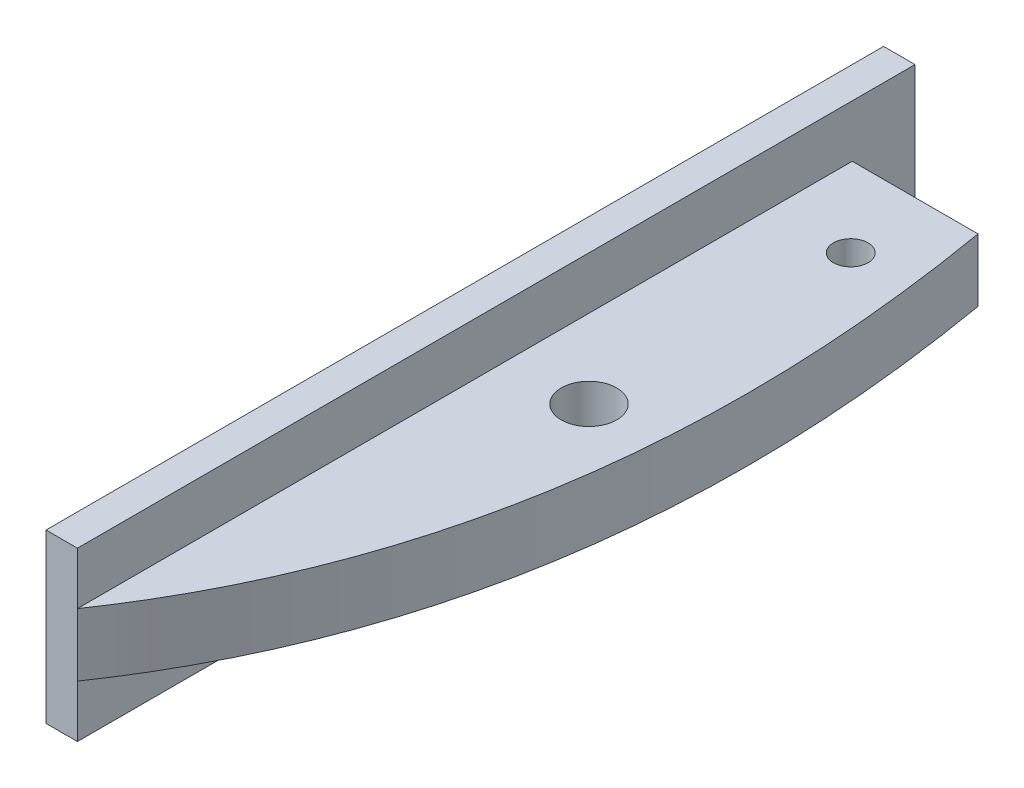
from build123d import *

# Parameters (mm, degrees)
SKETCH1_R                = 2.65
SKETCH1_R_2              = 1.65
BOSS_EXTRUDE1_DEPTH      = 6
SKETCH2_W                = 3
SKETCH2_H                = 84
BOSS_EXTRUDE2_DEPTH      = 5
BOSS_EXTRUDE2_DEPTH_BACK = 11
SKETCH3_W                = 3.872725059
SKETCH3_H                = 4
CUT_EXTRUDE2_DEPTH       = 10
CUT_EXTRUDE2_DEPTH_BACK  = 20


with BuildPart() as part:
    # Sketch1 → Boss-Extrude1 (new body)
    with BuildSketch(Plane(origin=(0, 0, 0), x_dir=(1, 0, 0), z_dir=(0, 1, 0))):
        with BuildLine():
            Line((10, 0), (0, 0))
            Line((0, 0), (0, -84))
            add(Edge.make_bspline(
                [(10, 0), (21.928320777, -51.98362607), (0, -84)],
                knots=[0, 0, 0, 0.5770461, 0.5770461, 0.5770461], degree=2))
        make_face()
        with Locations((7.5, -42.64)):
            Circle(SKETCH1_R, mode=Mode.SUBTRACT)
        with Locations((7.5, -17.64)):
            Circle(SKETCH1_R_2, mode=Mode.SUBTRACT)
    extrude(amount=BOSS_EXTRUDE1_DEPTH)

    # Sketch2 → Boss-Extrude2 (add, two sides)
    with BuildSketch(Plane(origin=(0, 6, 0), x_dir=(1, 0, 0), z_dir=(0, 1, 0))) as boss_extrude2_sk:
        with Locations((-1.5, -42)):
            Rectangle(SKETCH2_W, SKETCH2_H)
    extrude(amount=BOSS_EXTRUDE2_DEPTH)
    extrude(boss_extrude2_sk.sketch, amount=-BOSS_EXTRUDE2_DEPTH_BACK)

    # Sketch3 → Cut-Extrude2 (cut, two sides)
    with BuildSketch(Plane(origin=(0, 6, 0), x_dir=(1, 0, 0), z_dir=(0, 1, 0))) as cut_extrude2_sk:
        Polygon((23.981174241, 0), (0, 0), (0, -4), (0, -10), (23.981174241, -10), align=None)
        with Locations((-1.93636253, -2)):
            Rectangle(SKETCH3_W, SKETCH3_H)
    extrude(amount=CUT_EXTRUDE2_DEPTH, mode=Mode.SUBTRACT)
    extrude(cut_extrude2_sk.sketch, amount=-CUT_EXTRUDE2_DEPTH_BACK, mode=Mode.SUBTRACT)


solid = part.part
